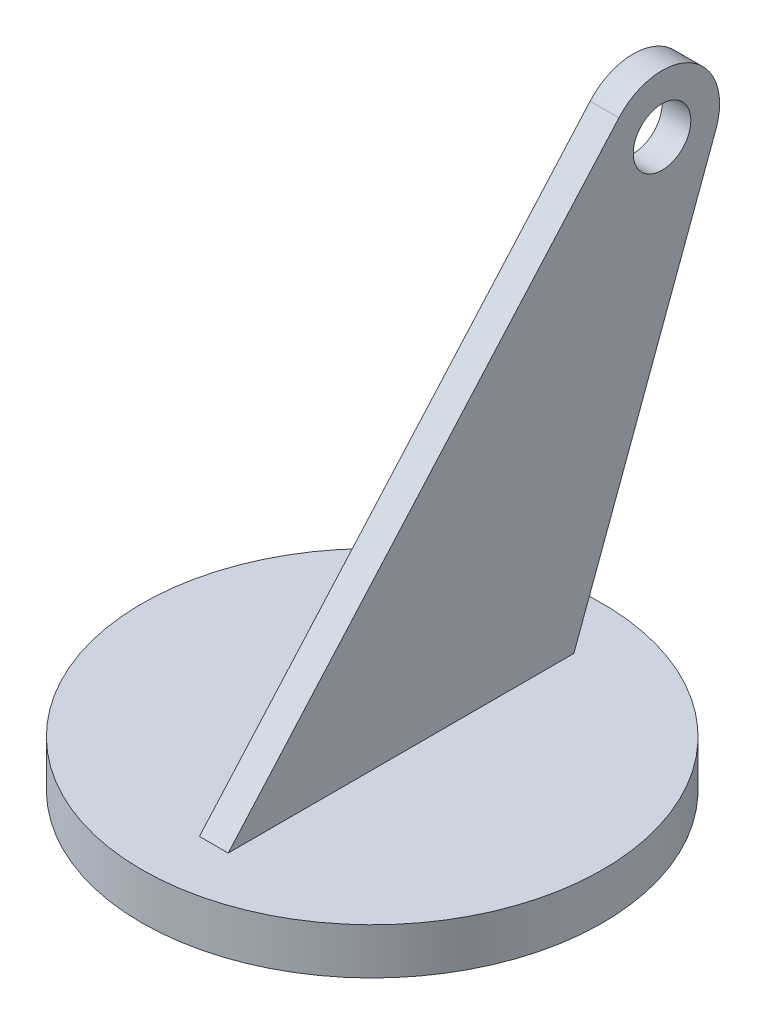
from build123d import *

# Parameters (mm, degrees)
SKETCH1_R           = 40
BOSS_EXTRUDE1_DEPTH = 4
SKETCH8_R           = 5
BOSS_EXTRUDE3_DEPTH = 5


with BuildPart() as part:
    # Sketch1 → Boss-Extrude1 (new body, symmetric)
    with BuildSketch(Plane(origin=(0, 0, 0), x_dir=(1, 0, 0), z_dir=(0, 1, 0))):
        Circle(SKETCH1_R)
    extrude(amount=BOSS_EXTRUDE1_DEPTH, both=True)

    # Sketch8 → Boss-Extrude3 (add)
    with BuildSketch(Plane(origin=(0, 0, 0), x_dir=(0, 0, -1), z_dir=(1, 0, 0))):
        with BuildLine():
            Line((0, 4), (-30, 4))
            Line((-30, 4), (37.824592442, 80.62784488))
            ThreePointArc((37.824592442, 80.62784488), (50.453649811, 82.577329326), (54.687857205, 70.520585679))
            Line((54.687857205, 70.520585679), (30, 4))
            Line((30, 4), (0, 4))
        make_face()
        with Locations((45.312694487, 74)):
            Circle(SKETCH8_R, mode=Mode.SUBTRACT)
    extrude(amount=BOSS_EXTRUDE3_DEPTH)


solid = part.part
